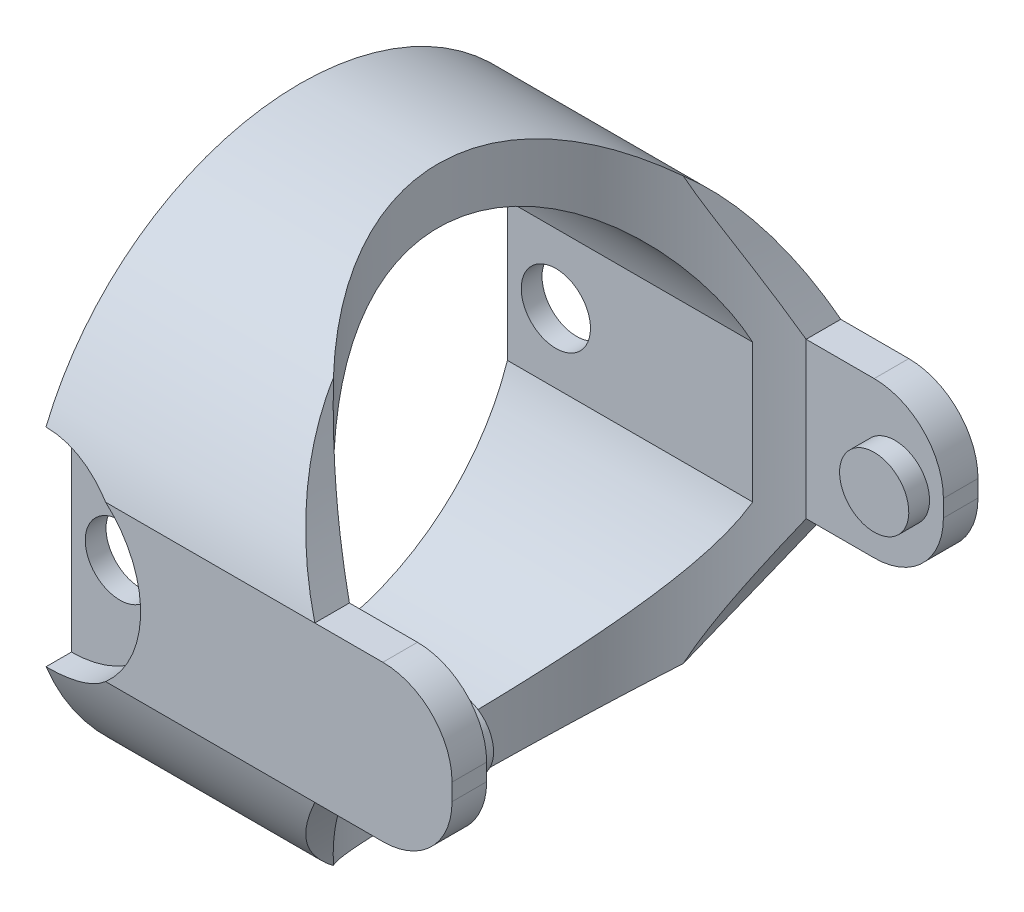
from build123d import *

# Parameters (mm, degrees)
DODANIE_WYCI_GNI_CIE2_DEPTH     = 6
SZKIC6_RX                       = 4
SZKIC6_RY                       = 3.8
WYTNIJ_WYCI_GNI_CIE4_DEPTH      = 4.96227766
WYTNIJ_WYCI_GNI_CIE4_DEPTH_BACK = 4.96227766
SZKIC10_W                       = 6
SZKIC10_H                       = 2.244677488
DODANIE_WYCI_GNI_CIE5_DEPTH     = 0.5
WYTNIJ_WYCI_GNI_CIE6_DEPTH      = 8.1000001
WYTNIJ_WYCI_GNI_CIE6_DEPTH_BACK = 1.5000001
ZAOKR_GLENIE3_R                 = 1
WYTNIJ_WYCI_GNI_CIE8_DEPTH      = 0.5
SZKIC14_R                       = 0.5
WYTNIJ_WYCI_GNI_CIE9_DEPTH      = 8.1000001
SZKIC12_R                       = 0.5
DODANIE_WYCI_GNI_CIE6_DEPTH     = 0.8
SKALA1_SCALE                    = 0.35


with BuildPart() as part:
    # Szkic4 → Dodanie-wyciągnięcie2 (new body)
    with BuildSketch(Plane(origin=(0, 0, 0), x_dir=(0, 0, -1), z_dir=(1, 0, 0))):
        with BuildLine():
            Line((-3.8, 1.122338744), (-3.8, -1.122338744))
            ThreePointArc((-3.8, -1.122338744), (0, -3.96227766), (3.8, -1.122338744))
            Line((3.8, -1.122338744), (3.8, 1.122338744))
            ThreePointArc((3.8, 1.122338744), (0, 3.96227766), (-3.8, 1.122338744))
        make_face()
        with BuildLine():
            ThreePointArc((3, 1), (0, 3.16227766), (-3, 1))
            Line((-3, 1), (-3, -1))
            ThreePointArc((-3, -1), (0, -3.16227766), (3, -1))
            Line((3, -1), (3, 1))
        make_face(mode=Mode.SUBTRACT)
    extrude(amount=DODANIE_WYCI_GNI_CIE2_DEPTH)

    # Szkic6 → Wytnij-wyciągnięcie4 (cut, two sides)
    with BuildSketch(Plane(origin=(0, 0, 0), x_dir=(1, 0, 0), z_dir=(0, 1, 0))) as wytnij_wyci_gni_cie4_sk:
        with Locations(Location((6, 0), (0, 0, 180))):
            Ellipse(SZKIC6_RX, SZKIC6_RY)
    extrude(amount=WYTNIJ_WYCI_GNI_CIE4_DEPTH, mode=Mode.SUBTRACT)
    extrude(wytnij_wyci_gni_cie4_sk.sketch, amount=-WYTNIJ_WYCI_GNI_CIE4_DEPTH_BACK, mode=Mode.SUBTRACT)

    # Szkic10 → Dodanie-wyciągnięcie5 (add)
    with BuildSketch(Plane.XY.offset(3.8)):
        with Locations((3, 0)):
            Rectangle(SZKIC10_W, SZKIC10_H)
    dodanie_wyci_gni_cie5 = extrude(amount=-DODANIE_WYCI_GNI_CIE5_DEPTH)

    # Szkic11 → Wytnij-wyciągnięcie6 (cut, two sides)
    with BuildSketch(Plane(origin=(0, 0, 3.3), x_dir=(-1, 0, 0), z_dir=(0, 0, -1))) as wytnij_wyci_gni_cie6_sk:
        with BuildLine():
            Line((-6, -3.622338744), (-2.871743963, -3.622338744))
            add(Edge.make_bspline(
                [(-4.016690139, -1.122338744), (-2.925616262, -2.903897768), (-2.871743963, -3.622338744)],
                knots=[0, 0, 0, 1, 1, 1], degree=2))
            Line((-4.016690139, -1.122338744), (-6, -1.122338744))
            Line((-6, -1.122338744), (-6, -3.622338744))
        make_face()
        with BuildLine():
            Line((-6, 1.122338744), (-4.016690139, 1.122338744))
            add(Edge.make_bspline(
                [(-4.016690139, 1.122338744), (-2.925616262, 2.903897768), (-2.871743963, 3.622338744)],
                knots=[0, 0, 0, 1, 1, 1], degree=2))
            Line((-2.871743963, 3.622338744), (-6, 3.622338744))
            Line((-6, 3.622338744), (-6, 1.122338744))
        make_face()
    extrude(amount=WYTNIJ_WYCI_GNI_CIE6_DEPTH, mode=Mode.SUBTRACT)
    extrude(wytnij_wyci_gni_cie6_sk.sketch, amount=-WYTNIJ_WYCI_GNI_CIE6_DEPTH_BACK, mode=Mode.SUBTRACT)

    # Lustro2: Dodanie-wyciągnięcie5 across plane
    add(dodanie_wyci_gni_cie5.mirror(Plane.XY))

    # Zaokrąglenie3
    zaokr_glenie3_edges = [part.edges().sort_by_distance(p)[0] for p in [
        (6, 1.122338744, -3.55),
        (6, -1.122338744, -3.55),
        (6, -1.122338744, 3.55),
        (6, 1.122338744, 3.55),
    ]]
    fillet(zaokr_glenie3_edges, radius=ZAOKR_GLENIE3_R)

    # Szkic13 → Wytnij-wyciągnięcie8 (cut)
    with BuildSketch(Plane.XY.offset(3.8)):
        with BuildLine():
            Line((0, 1.5), (0, -1.5))
            ThreePointArc((0, -1.5), (1.5, 0), (0, 1.5))
        make_face()
    wytnij_wyci_gni_cie8 = extrude(amount=-WYTNIJ_WYCI_GNI_CIE8_DEPTH, mode=Mode.SUBTRACT)

    # Lustro3: Wytnij-wyciągnięcie8 across plane
    add(wytnij_wyci_gni_cie8.mirror(Plane.XY), mode=Mode.SUBTRACT)

    # Szkic14 → Wytnij-wyciągnięcie9 (cut, through all)
    with BuildSketch(Plane.XY.offset(3.3)):
        with Locations(Location((0.7, 0, 0), (0, 0, 90))):  # turned: the seam where the file's is
            Circle(SZKIC14_R)
    extrude(amount=-WYTNIJ_WYCI_GNI_CIE9_DEPTH, mode=Mode.SUBTRACT)

    # Szkic12 → Dodanie-wyciągnięcie6 (add)
    with BuildSketch(Plane(origin=(0, 0, -3.8), x_dir=(-1, 0, 0), z_dir=(0, 0, -1))):
        with Locations(Location((-5.3, 0, 0), (0, 0, 90))):  # turned: the seam where the file's is
            Circle(SZKIC12_R)
    dodanie_wyci_gni_cie6 = extrude(amount=-DODANIE_WYCI_GNI_CIE6_DEPTH)

    # Lustro4: Dodanie-wyciągnięcie6 across plane
    add(dodanie_wyci_gni_cie6.mirror(Plane.XY))


with BuildPart() as part_1:
    # Skala1: scaled about (1.935517978, -1.129e-06, 5.07e-07)
    add(part.part.scale(SKALA1_SCALE).moved(Location((1.258086686, -7.34e-07, 3.3e-07))))


solid = part_1.part
